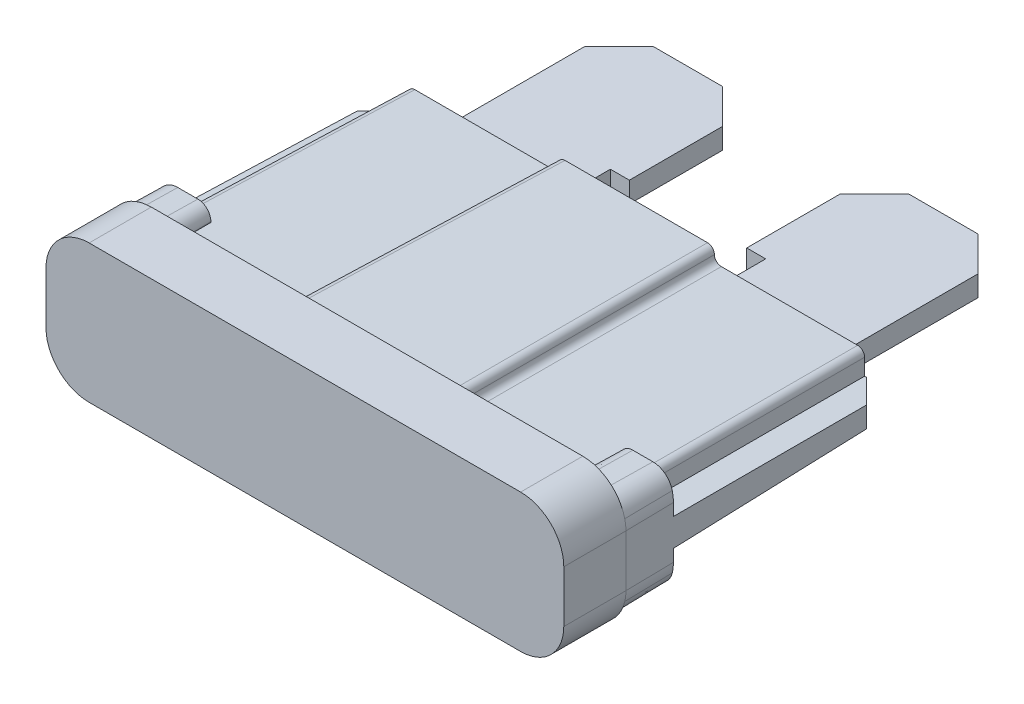
from build123d import *

# Parameters (mm, degrees)
SKETCH1_W                       = 19.05
SKETCH1_H                       = 5.08
BASE_EXTRUDE_DEPTH              = 2.286
FILLET1_R                       = 1.5875
BOSS_EXTRUDE3_DEPTH             = 9.906
BOSS_EXTRUDE3_TAPER             = 1
FILLET4_R                       = 0.254
BOSS_EXTRUDE4_DEPTH             = 1.778
BOSS_EXTRUDE4_TAPER             = 1
SKETCH5_W                       = 1.861791545
SKETCH5_H                       = 1.016
BOSS_EXTRUDE6_DEPTH             = 8.128
BOSS_EXTRUDE6_TAPER             = 1
CHAMFER1_SIZE                   = 0.889
CHAMFER1_SIZE2                  = 0.90493105
CHAMFER1_EDGE_2_SIZE            = 0.889
CHAMFER1_EDGE_2_SIZE2           = 0.90493105
BLADES_DEPTH                    = 0.381
SCHNITT_LINEAR_AUSTRAGEN1_DEPTH = 0.05


with BuildPart() as part:
    # Sketch1 → Base-Extrude (new body)
    with BuildSketch(Plane.XY):
        Rectangle(SKETCH1_W, SKETCH1_H)
    extrude(amount=-BASE_EXTRUDE_DEPTH)

    # Fillet1
    fillet1_edges = [part.edges().sort_by_distance(p)[0] for p in [
        (-9.525, 2.54, -1.143),
        (9.525, 2.54, -1.143),
        (9.525, -2.54, -1.143),
        (-9.525, -2.54, -1.143),
    ]]
    fillet(fillet1_edges, radius=FILLET1_R)

    # Sketch2 → Boss-Extrude3 (add)
    with BuildSketch(Plane(origin=(0, 0, -2.286), x_dir=(-1, 0, 0), z_dir=(0, 0, -1))):
        Polygon((-3.048, 1.905), (-3.048, 1.397), (-8.5725, 1.397), (-8.5725, -1.397), (-3.048, -1.397), (-3.048, -1.905), (3.048, -1.905), (3.048, -1.397), (8.5725, -1.397), (8.5725, 1.397), (3.048, 1.397), (3.048, 1.905), align=None)
    extrude(amount=BOSS_EXTRUDE3_DEPTH, taper=BOSS_EXTRUDE3_TAPER)

    # Fillet4
    fillet4_edges = [part.edges().sort_by_distance(p)[0] for p in [
        (-2.961545063, 1.818545063, -7.239),
        (-2.961545063, 1.310545063, -7.239),
        (-8.486045063, 1.310545063, -7.239),
        (-8.486045063, -1.310545063, -7.239),
        (-2.961545063, -1.310545063, -7.239),
        (-2.961545063, -1.818545063, -7.239),
        (2.961545063, -1.818545063, -7.239),
        (2.961545063, -1.310545063, -7.239),
        (8.486045063, -1.310545063, -7.239),
        (8.486045063, 1.310545063, -7.239),
        (2.961545063, 1.310545063, -7.239),
        (2.961545063, 1.818545063, -7.239),
    ]]
    fillet(fillet4_edges, radius=FILLET4_R)

    # Sketch3 → Boss-Extrude4 (add)
    with BuildSketch(Plane(origin=(0, 0, -2.286), x_dir=(-1, 0, 0), z_dir=(0, 0, -1))):
        with BuildLine():
            ThreePointArc((-9.525, -0.9525), (-9.514251364, -1.136921759), (-9.482151011, -1.318846154))
            ThreePointArc((-9.482151011, -1.318846154), (-9.213290864, -1.74076198), (-8.740718526, -1.905))
            Line((-8.740718526, -1.905), (-8.001, -1.905))
            ThreePointArc((-8.001, -1.905), (-7.641789755, -1.756210245), (-7.493, -1.397))
            Line((-7.493, -1.397), (-7.493, 1.397))
            ThreePointArc((-7.493, 1.397), (-7.641789755, 1.756210245), (-8.001, 1.905))
            Line((-8.001, 1.905), (-8.740718526, 1.905))
            ThreePointArc((-8.740718526, 1.905), (-9.213290864, 1.74076198), (-9.482151011, 1.318846154))
            ThreePointArc((-9.482151011, 1.318846154), (-9.514251364, 1.136921759), (-9.525, 0.9525))
            Line((-9.525, 0.9525), (-9.525, -0.9525))
        make_face()
        with BuildLine():
            ThreePointArc((8.740718526, -1.905), (9.213290864, -1.74076198), (9.482151011, -1.318846154))
            ThreePointArc((9.482151011, -1.318846154), (9.514251364, -1.136921759), (9.525, -0.9525))
            Line((9.525, -0.9525), (9.525, 0.9525))
            ThreePointArc((9.525, 0.9525), (9.514251364, 1.136921759), (9.482151011, 1.318846154))
            ThreePointArc((9.482151011, 1.318846154), (9.213290864, 1.74076198), (8.740718526, 1.905))
            Line((8.740718526, 1.905), (8.001, 1.905))
            ThreePointArc((8.001, 1.905), (7.641789755, 1.756210245), (7.493, 1.397))
            Line((7.493, 1.397), (7.493, -1.397))
            ThreePointArc((7.493, -1.397), (7.641789755, -1.756210245), (8.001, -1.905))
            Line((8.001, -1.905), (8.740718526, -1.905))
        make_face()
    extrude(amount=BOSS_EXTRUDE4_DEPTH, taper=BOSS_EXTRUDE4_TAPER)

    # Sketch5 → Boss-Extrude6 (add)
    with BuildSketch(Plane(origin=(0, 0, -4.064), x_dir=(-1, 0, 0), z_dir=(0, 0, -1))):
        with Locations((-8.563069122, 0)):
            Rectangle(SKETCH5_W, SKETCH5_H)
        with Locations((8.563069122, 0)):
            Rectangle(SKETCH5_W, SKETCH5_H)
    extrude(amount=BOSS_EXTRUDE6_DEPTH, taper=BOSS_EXTRUDE6_TAPER)

    # Chamfer1
    chamfer1_edges = [part.edges().sort_by_distance(p)[0] for p in [
        (9.352090127, 0, -12.192),
    ]]
    chamfer1_side = [part.faces().sort_by_distance(p)[0] for p in [
        (4e-09, -1.6e-08, -12.192),
    ]]
    chamfer(chamfer1_edges, length=CHAMFER1_SIZE, length2=CHAMFER1_SIZE2, reference=chamfer1_side[0])

    # Chamfer1 edge 2
    chamfer1_edge_2_edges = [part.edges().sort_by_distance(p)[0] for p in [
        (-9.352090127, 0, -12.192),
    ]]
    chamfer1_edge_2_side = [part.faces().sort_by_distance(p)[0] for p in [
        (4e-09, -1.6e-08, -12.192),
    ]]
    chamfer(chamfer1_edge_2_edges, length=CHAMFER1_EDGE_2_SIZE, length2=CHAMFER1_EDGE_2_SIZE2, reference=chamfer1_edge_2_side[0])

    # Sketch6 → Blades (add, symmetric)
    with BuildSketch(Plane(origin=(0, 0, 0), x_dir=(1, 0, 0), z_dir=(0, 1, 0))):
        Polygon((-7.239, 12.192), (-7.239, 17.526), (-5.969, 18.796), (-3.429, 18.796), (-2.159, 17.526), (-2.159, 14.097), (-2.8575, 14.097), (-2.8575, 12.192), align=None)
        Polygon((2.8575, 12.192), (7.239, 12.192), (7.239, 17.526), (5.969, 18.796), (3.429, 18.796), (2.159, 17.526), (2.159, 14.097), (2.8575, 14.097), align=None)
    extrude(amount=BLADES_DEPTH, both=True)

    # Skizze1 → Schnitt-Linear austragen1 (cut)
    with BuildSketch(Plane(origin=(0, -1.944309887, -0.033938055), x_dir=(1, 0, 0), z_dir=(0, -0.999847695, -0.017452406))):
        Polygon((-1.614970101, -3.772798227), (-1.337626351, -3.772798227), (-1.337626351, -5.272798227), (-1.472241735, -5.272798227), (-1.472241735, -3.926644381), (-1.703010966, -3.926644381), align=None)
        with BuildLine():
            Line((0.162373649, -3.772798227), (0.162373649, -3.926644381))
            Line((0.162373649, -3.926644381), (-0.347842697, -3.926644381))
            Line((-0.347842697, -3.926644381), (-0.428672024, -4.321175631))
            add(Edge.make_bspline(
                [(-0.428672024, -4.321175631), (-0.412790935, -4.316791229), (-0.382023836, -4.308297143), (-0.336612467, -4.298866099), (-0.293501523, -4.293180908), (-0.265526364, -4.292404633), (-0.251989331, -4.292028997)],
                knots=[0, 0, 0, 0, 1.100273476, 2.13160584, 3.095893838, 4, 4, 4, 4], degree=3))
            add(Edge.make_bspline(
                [(-0.251989331, -4.292028997), (-0.235239157, -4.292391541), (-0.20230413, -4.293104392), (-0.15411601, -4.299949471), (-0.108116198, -4.31072372), (-0.064400897, -4.325775372), (-0.022889232, -4.345022401), (0.016036866, -4.369065232), (0.052961685, -4.397150945), (0.087222797, -4.429441665), (0.118304643, -4.464979501), (0.145632925, -4.503190017), (0.168845463, -4.543701872), (0.187514358, -4.586902133), (0.20242193, -4.632313199), (0.212344214, -4.680412877), (0.218951375, -4.730747785), (0.21968954, -4.76516403), (0.220065957, -4.782714093)],
                knots=[0, 0, 0, 0, 1.052922333, 2.070308379, 3.05430497, 4.020497103, 4.973039431, 5.925935799, 6.892292201, 7.88610001, 8.88166317, 9.857072816, 10.836096531, 11.812156883, 12.81219415, 13.836441305, 14.89672472, 16, 16, 16, 16], degree=3))
            add(Edge.make_bspline(
                [(0.220065957, -4.782714093), (0.219780925, -4.794937902), (0.219214712, -4.819220325), (0.216335318, -4.855282125), (0.210791439, -4.890580482), (0.203348129, -4.925120079), (0.193687093, -4.958835524), (0.181991784, -4.991823322), (0.167679201, -5.023878153), (0.15198004, -5.055303322), (0.134302978, -5.085388397), (0.114683618, -5.113523677), (0.09395555, -5.140131226), (0.071652099, -5.164925683), (0.047565958, -5.187744119), (0.02198883, -5.208721954), (-0.004875193, -5.228213953), (-0.033441725, -5.245428894), (-0.063074218, -5.261270161), (-0.094200597, -5.274265962), (-0.126112326, -5.28588476), (-0.159268701, -5.295145986), (-0.193594621, -5.302402795), (-0.229146667, -5.307331624), (-0.265738383, -5.310921526), (-0.29054196, -5.31114625), (-0.303071062, -5.311259766)],
                knots=[0, 0, 0, 0, 1.056347294, 2.098418968, 3.122841568, 4.141288669, 5.149314143, 6.15115421, 7.162517403, 8.180376062, 9.185164535, 10.17417709, 11.141909838, 12.097768115, 13.052685741, 14.0056014, 14.954263652, 15.917497458, 16.885230207, 17.854509472, 18.828990115, 19.81800267, 20.826176721, 21.857883937, 22.917946725, 24, 24, 24, 24], degree=3))
            add(Edge.make_bspline(
                [(-0.303071062, -5.311259766), (-0.31801714, -5.310963693), (-0.347421781, -5.310381203), (-0.390502024, -5.304287566), (-0.431951141, -5.295560174), (-0.47143547, -5.282430344), (-0.509308869, -5.265978646), (-0.545061462, -5.245186001), (-0.579606795, -5.221623528), (-0.611540525, -5.193817663), (-0.641178859, -5.163425227), (-0.66771022, -5.130443381), (-0.691338896, -5.095416477), (-0.711686502, -5.058174411), (-0.729042797, -5.018815041), (-0.742677792, -4.977190898), (-0.753682801, -4.933519468), (-0.758338552, -4.903453677), (-0.760703274, -4.888182843)],
                knots=[0, 0, 0, 0, 1.0467383, 2.05933395, 3.04377827, 4.011590433, 4.970194871, 5.932262533, 6.905835911, 7.896367577, 8.894135286, 9.877477877, 10.858688626, 11.851381753, 12.8477658, 13.868841284, 14.917554742, 16, 16, 16, 16], degree=3))
            Line((-0.760703274, -4.888182843), (-0.626087889, -4.888182843))
            add(Edge.make_bspline(
                [(-0.626087889, -4.888182843), (-0.62277565, -4.902487037), (-0.616409343, -4.929980492), (-0.602435451, -4.968608209), (-0.585350076, -5.003030734), (-0.565033926, -5.033703412), (-0.540798199, -5.060450126), (-0.513142729, -5.084286009), (-0.482136562, -5.105789636), (-0.447682321, -5.123713679), (-0.411333858, -5.139000288), (-0.373290768, -5.149179586), (-0.334588906, -5.156337111), (-0.308412461, -5.15705358), (-0.295258562, -5.157413612)],
                knots=[0, 0, 0, 0, 1.136247022, 2.183929868, 3.172523383, 4.106158343, 5.02341133, 5.958108904, 6.928429099, 7.938127109, 8.96079061, 9.975095812, 10.982467395, 12, 12, 12, 12], degree=3))
            add(Edge.make_bspline(
                [(-0.295258562, -5.157413612), (-0.282419229, -5.15706185), (-0.257138476, -5.156369228), (-0.219933596, -5.151038223), (-0.184013793, -5.142827835), (-0.149733497, -5.130540754), (-0.116492838, -5.115607304), (-0.08513265, -5.0964437), (-0.054745703, -5.074389406), (-0.026276503, -5.049122279), (-0.000202453, -5.021278124), (0.022835884, -4.991502098), (0.04202599, -4.959737736), (0.058197751, -4.926534956), (0.070477736, -4.89152986), (0.079238157, -4.854886499), (0.084382325, -4.816514365), (0.085089974, -4.790341803), (0.085450572, -4.777004958)],
                knots=[0, 0, 0, 0, 1.027316725, 2.022795036, 3.002884548, 3.971462791, 4.93288096, 5.914575861, 6.907176829, 7.935150275, 8.956128384, 9.956726525, 10.942570165, 11.921478529, 12.907843606, 13.90538589, 14.932640048, 16, 16, 16, 16], degree=3))
            add(Edge.make_bspline(
                [(0.085450572, -4.777004958), (0.085168367, -4.764972493), (0.08461599, -4.741420655), (0.080102888, -4.706963852), (0.072252757, -4.67436112), (0.061356809, -4.64345502), (0.047522734, -4.614216401), (0.030617172, -4.58661509), (0.010322858, -4.561014876), (-0.01285938, -4.537403781), (-0.038255683, -4.515613121), (-0.066303001, -4.497037084), (-0.096414398, -4.48140969), (-0.128227084, -4.467923405), (-0.162497755, -4.458237372), (-0.19854774, -4.450965421), (-0.236766329, -4.446758837), (-0.262896624, -4.44617517), (-0.276328274, -4.445875151)],
                knots=[0, 0, 0, 0, 1.045622112, 2.046656509, 3.013763289, 3.955457236, 4.890082067, 5.820317437, 6.762574623, 7.722996705, 8.69280354, 9.665887285, 10.63943826, 11.638615906, 12.663482002, 13.728887084, 14.832589034, 16, 16, 16, 16], degree=3))
            add(Edge.make_bspline(
                [(-0.276328274, -4.445875151), (-0.287954957, -4.446123975), (-0.31196111, -4.446637735), (-0.348785178, -4.45042052), (-0.387481631, -4.456523074), (-0.427902129, -4.464917181), (-0.470168061, -4.475901928), (-0.514190233, -4.489065285), (-0.560061204, -4.504803285), (-0.5909688, -4.516688519), (-0.60685712, -4.522798227)],
                knots=[0, 0, 0, 0, 0.817624296, 1.688186739, 2.600797293, 3.572016777, 4.590301741, 5.671205678, 6.80286297, 8, 8, 8, 8], degree=3))
            Line((-0.60685712, -4.522798227), (-0.453010966, -3.772798227))
            Line((-0.453010966, -3.772798227), (0.162373649, -3.772798227))
        make_face()
        Polygon((1.123912111, -3.772798227), (1.816219803, -5.272798227), (1.669885669, -5.272798227), (1.448130861, -4.792028997), (0.76814288, -4.792028997), (0.540077976, -5.272798227), (0.39314288, -5.272798227), (1.104681342, -3.772798227), align=None)
        Polygon((1.112794322, -4.065166016), (0.841159707, -4.638182843), (1.377217399, -4.638182843), align=None, mode=Mode.SUBTRACT)
    extrude(amount=-SCHNITT_LINEAR_AUSTRAGEN1_DEPTH, mode=Mode.SUBTRACT)


solid = part.part
